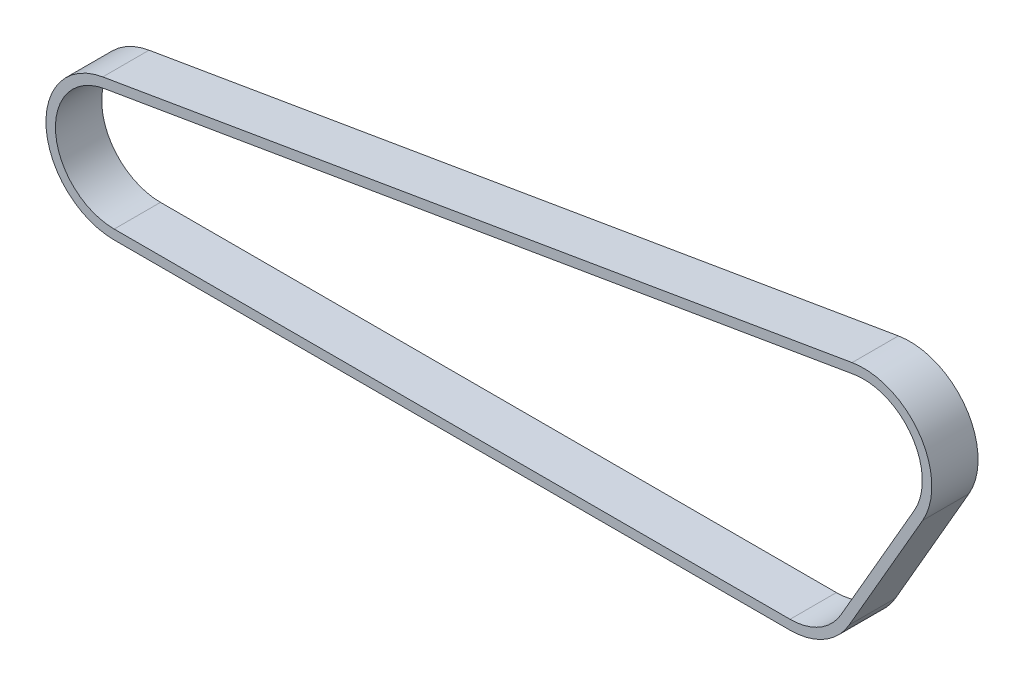
from build123d import *

# Parameters (mm, degrees)
BOSS_EXTRUDE1_DEPTH = 10


with BuildPart() as part:
    # Sketch3 → Boss-Extrude1 (new body, symmetric)
    with BuildSketch(Plane.XY):
        with BuildLine():
            Line((-328.788665285, -25.908947876), (-4.938665285, 29.083665264))
            ThreePointArc((-4.938665285, 29.083665264), (24.21840498, 16.843956193), (25.547749412, -14.75))
            Line((25.547749412, -14.75), (-6.202250588, -69.74261314))
            ThreePointArc((-6.202250588, -69.74261314), (-17, -80.540362552), (-31.75, -84.49261314))
            Line((-31.75, -84.49261314), (-323.85, -84.49261314))
            ThreePointArc((-323.85, -84.49261314), (-353.245732048, -57.470704614), (-328.788665285, -25.908947876))
        make_face()
        with BuildLine():
            Line((-328.102274517, -29.951084404), (-4.252274517, 25.041528736))
            ThreePointArc((-4.252274517, 25.041528736), (20.852457169, 14.502931773), (21.997045256, -12.7))
            Line((21.997045256, -12.7), (-9.752954744, -67.69261314))
            ThreePointArc((-9.752954744, -67.69261314), (-19.05, -76.989658396), (-31.75, -80.39261314))
            Line((-31.75, -80.39261314), (-323.85, -80.39261314))
            ThreePointArc((-323.85, -80.39261314), (-349.160223526, -57.126291901), (-328.102274517, -29.951084404))
        make_face(mode=Mode.SUBTRACT)
    extrude(amount=BOSS_EXTRUDE1_DEPTH, both=True)


solid = part.part
